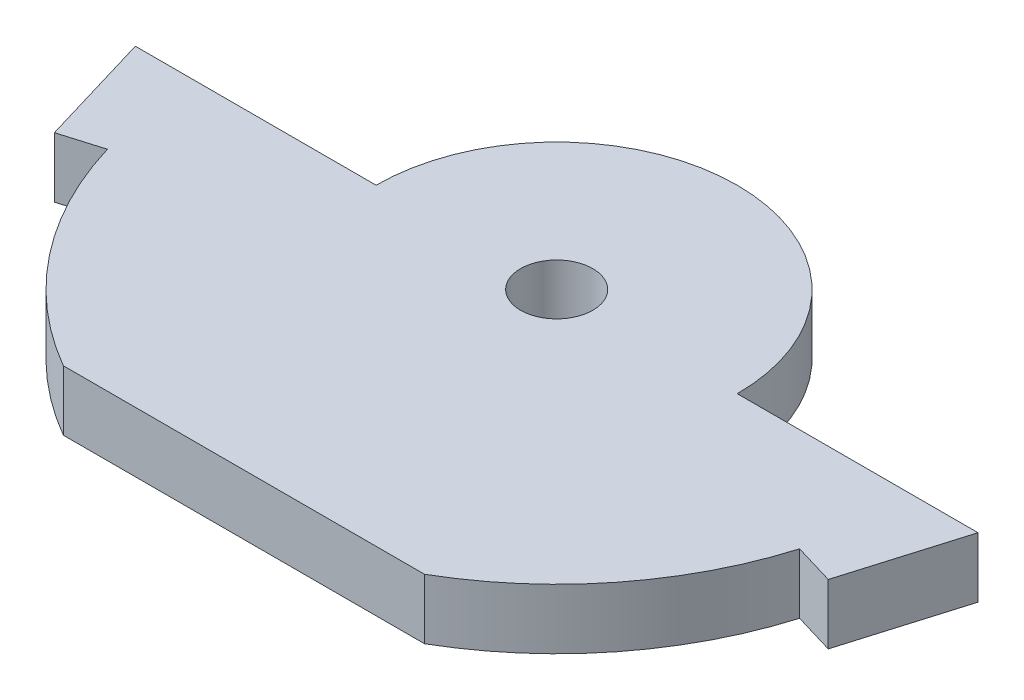
from build123d import *

# Parameters (mm, degrees)
SKETCH1_R           = 3
BOSS_EXTRUDE1_DEPTH = 5


with BuildPart() as part:
    # Sketch1 → Boss-Extrude1 (new body)
    with BuildSketch(Plane(origin=(0, 0, 0), x_dir=(1, 0, 0), z_dir=(0, 1, 0))):
        with BuildLine():
            ThreePointArc((15, 0), (0, 15), (-15, 0))
            Line((-15, 0), (-30, 0))
            Line((-30, 0), (-35, 0))
            Line((-35, 0), (-32.142857143, -9.583148475))
            Line((-32.142857143, -9.583148475), (-28.749445425, -8.571428571))
            ThreePointArc((-28.749445425, -8.571428571), (-23.543039679, -18.593689323), (-15, -25.980762114))
            Line((-15, -25.980762114), (15, -25.980762114))
            ThreePointArc((15, -25.980762114), (23.543039679, -18.593689323), (28.749445425, -8.571428571))
            Line((28.749445425, -8.571428571), (32.142857143, -9.583148475))
            Line((32.142857143, -9.583148475), (35, 0))
            Line((35, 0), (30, 0))
            Line((30, 0), (15, 0))
        make_face()
        Circle(SKETCH1_R, mode=Mode.SUBTRACT)
    extrude(amount=BOSS_EXTRUDE1_DEPTH)


solid = part.part
